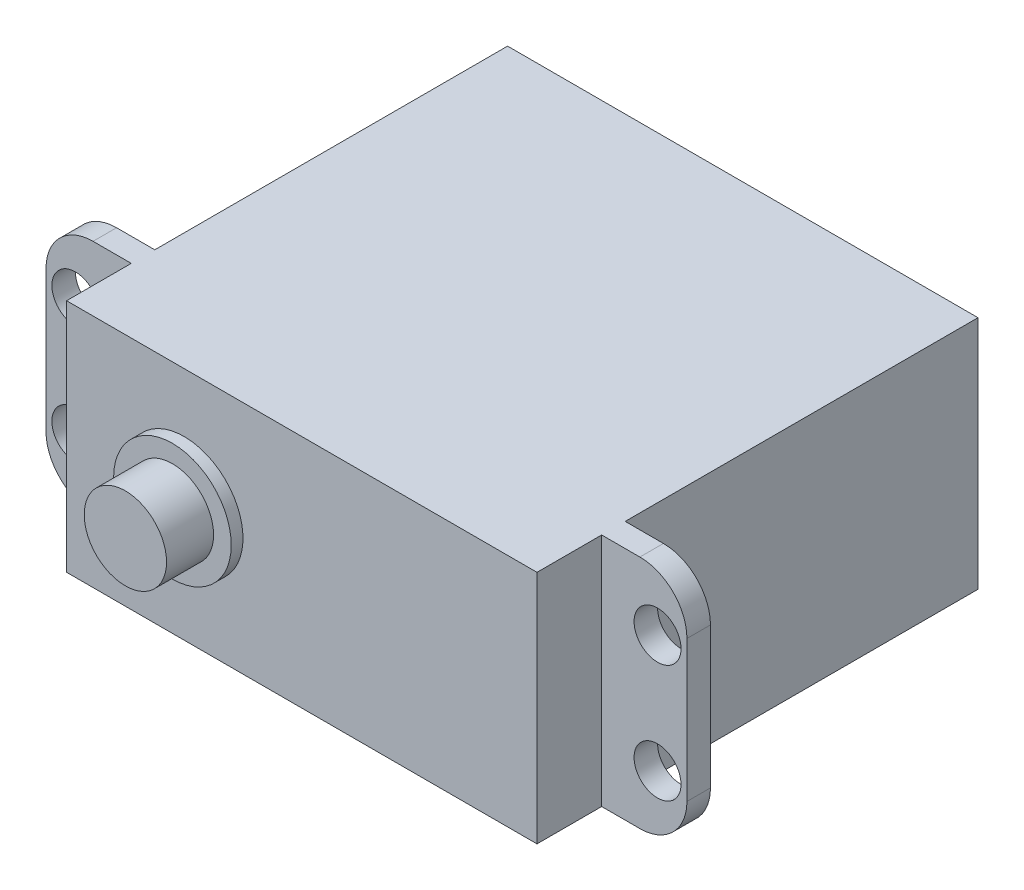
from build123d import *

# Parameters (mm, degrees)
SKETCH1_W           = 40
SKETCH1_H           = 20
BOSS_EXTRUDE2_DEPTH = 37.5
SKETCH2_W           = 2
SKETCH2_H           = 20
BOSS_EXTRUDE3_DEPTH = 7.25
SKETCH3_R           = 1.995473195
CUT_EXTRUDE1_DEPTH  = 2
FILLET3_R           = 4
SKETCH4_W           = 2
SKETCH4_H           = 20
BOSS_EXTRUDE4_DEPTH = 7.25
SKETCH5_R           = 2
CUT_EXTRUDE2_DEPTH  = 2
FILLET4_R           = 4
SKETCH6_R           = 5
BOSS_EXTRUDE5_DEPTH = 1
SKETCH7_R           = 3.5
BOSS_EXTRUDE7_DEPTH = 4


with BuildPart() as part:
    # Sketch1 → Boss-Extrude2 (new body)
    with BuildSketch(Plane.XY):
        Rectangle(SKETCH1_W, SKETCH1_H)
    extrude(amount=BOSS_EXTRUDE2_DEPTH)

    # Sketch2 → Boss-Extrude3 (add)
    with BuildSketch(Plane(origin=(20, 0, 0), x_dir=(0, 0, -1), z_dir=(1, 0, 0))):
        with Locations((-31, 0)):
            Rectangle(SKETCH2_W, SKETCH2_H)
    extrude(amount=BOSS_EXTRUDE3_DEPTH)

    # Sketch3 → Cut-Extrude1 (cut)
    with BuildSketch(Plane.XY.offset(32)):
        with Locations((24.75, -4.99913934)):
            Circle(SKETCH3_R)
        with Locations((24.75, 4.999429987)):
            Circle(SKETCH3_R)
    extrude(amount=-CUT_EXTRUDE1_DEPTH, mode=Mode.SUBTRACT)

    # Fillet3
    fillet3_edges = [part.edges().sort_by_distance(p)[0] for p in [
        (27.25, -10, 31),
        (27.25, 10, 31),
    ]]
    fillet(fillet3_edges, radius=FILLET3_R)

    # Sketch4 → Boss-Extrude4 (add)
    with BuildSketch(Plane.ZY.offset(20)):
        with Locations((31, 0)):
            Rectangle(SKETCH4_W, SKETCH4_H)
    extrude(amount=BOSS_EXTRUDE4_DEPTH)

    # Sketch5 → Cut-Extrude2 (cut)
    with BuildSketch(Plane.XY.offset(32)):
        with Locations((-24.75, 5)):
            Circle(SKETCH5_R)
        with Locations((-24.75, -5)):
            Circle(SKETCH5_R)
    extrude(amount=-CUT_EXTRUDE2_DEPTH, mode=Mode.SUBTRACT)

    # Fillet4
    fillet4_edges = [part.edges().sort_by_distance(p)[0] for p in [
        (-27.25, -10, 31),
        (-27.25, 10, 31),
    ]]
    fillet(fillet4_edges, radius=FILLET4_R)

    # Sketch6 → Boss-Extrude5 (add)
    with BuildSketch(Plane.XY.offset(37.5)):
        with Locations((-10, 0)):
            Circle(SKETCH6_R)
    extrude(amount=BOSS_EXTRUDE5_DEPTH)

    # Sketch7 → Boss-Extrude7 (add)
    with BuildSketch(Plane.XY.offset(38.5)):
        with Locations((-10, 0)):
            Circle(SKETCH7_R)
    extrude(amount=BOSS_EXTRUDE7_DEPTH)


solid = part.part
